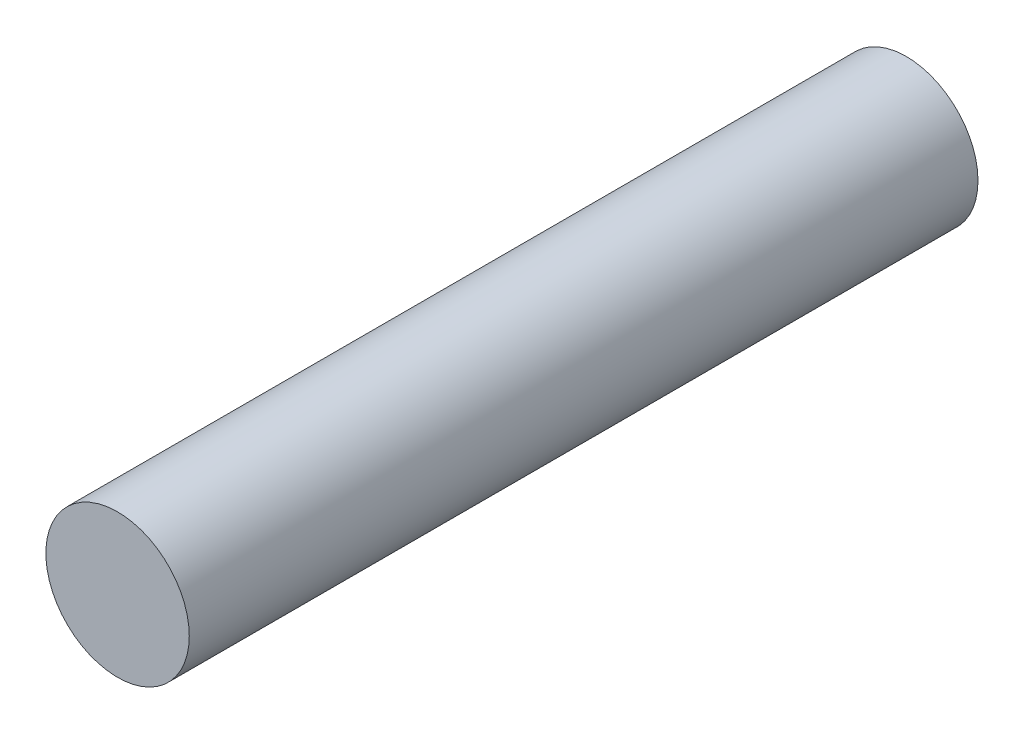
from build123d import *

# Parameters (mm, degrees)
BOSS_EXTRU_1_DEPTH      = 55
BOSS_EXTRU_1_DEPTH_BACK = 55
ESQUISSE1_R             = 10


with BuildPart() as part:
    # Esquisse1 → Boss.-Extru.1 (new, two sides: drawn at the far end of the back side and taken through both)
    with BuildSketch(Plane.XY.offset(-BOSS_EXTRU_1_DEPTH_BACK)):
        Circle(ESQUISSE1_R)
    extrude(amount=BOSS_EXTRU_1_DEPTH + BOSS_EXTRU_1_DEPTH_BACK)


solid = part.part
